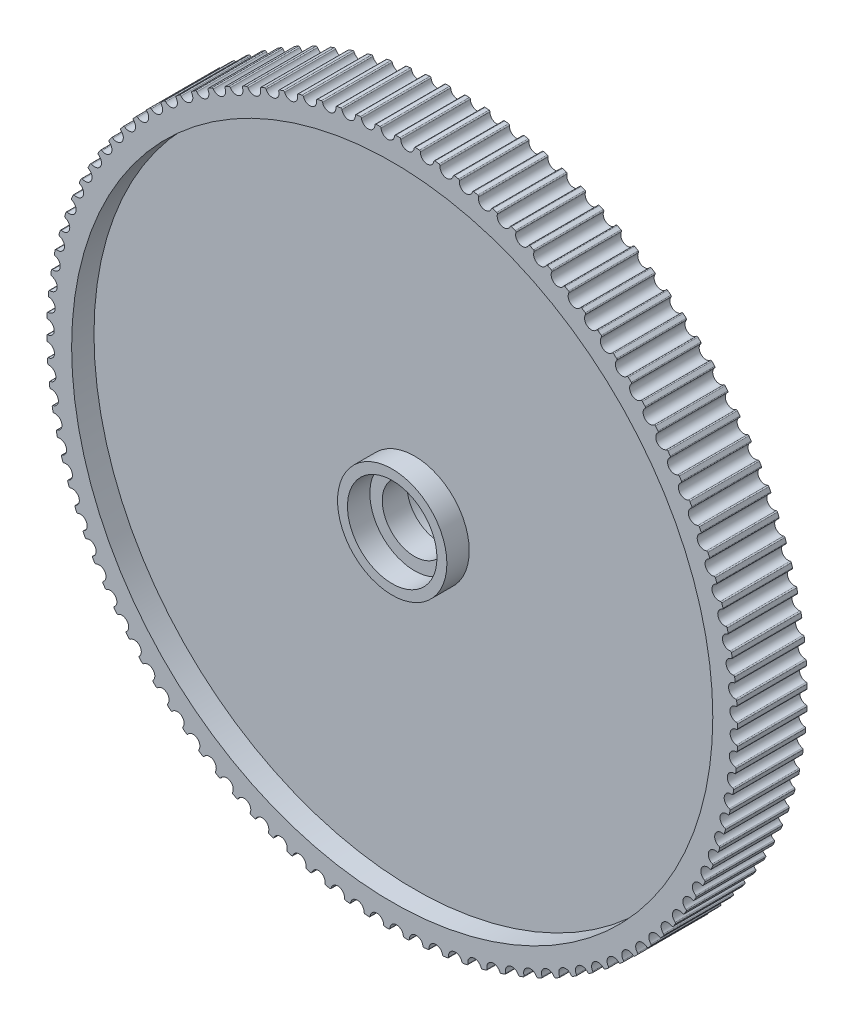
from build123d import *

# Parameters (mm, degrees)
BOSS_EXTRUDE1_DEPTH = 3.5
SKETCH4_R           = 32.25
CUT_EXTRUDE2_DEPTH  = 3.5
SKETCH6_R           = 32.25
SKETCH6_R_2         = 5.5
SKETCH6_R_3         = 4.5
SKETCH6_R_4         = 3.25
BOSS_EXTRUDE2_DEPTH = 1.25
SKETCH6_3_R         = 5.5
SKETCH6_3_R_2       = 4.5
BOSS_EXTRUDE3_DEPTH = 3.5


with BuildPart() as part:
    # Sketch2 → Boss-Extrude1 (new, symmetric)
    with BuildSketch(Plane.XY):
        with BuildLine():
            ThreePointArc((-3.211333328, 34.601298216), (-3.132582306, 34.577768977), (-3.092122191, 34.506226488))
            ThreePointArc((-3.092122191, 34.506226488), (-2.370608918, 33.917255392), (-1.738041502, 34.600868455))
            ThreePointArc((-1.738041502, 34.600868455), (-1.707926922, 34.677343683), (-1.633214692, 34.711599067))
            ThreePointArc((-1.633214692, 34.711599067), (-1.432005901, 34.720481839), (-1.230749008, 34.728198296))
            ThreePointArc((-1.230749008, 34.728198296), (-1.153469677, 34.700211628), (-1.117159824, 34.626475997))
            ThreePointArc((-1.117159824, 34.626475997), (-0.430446923, 33.997275118), (0.240115498, 34.643660757))
            ThreePointArc((0.240115498, 34.643660757), (0.274546844, 34.718292057), (0.351092826, 34.748226341))
            ThreePointArc((0.351092826, 34.748226341), (0.552480572, 34.745607855), (0.75384976, 34.741822211))
            ThreePointArc((0.75384976, 34.741822211), (0.829405331, 34.709469401), (0.861446487, 34.63378114))
            ThreePointArc((0.861446487, 34.63378114), (1.5111191, 33.966402798), (2.217489291, 34.573452638))
            ThreePointArc((2.217489291, 34.573452638), (2.256125096, 34.645996578), (2.334255151, 34.671512123))
            ThreePointArc((2.334255151, 34.671512123), (2.535164969, 34.657400921), (2.735989626, 34.642125523))
            ThreePointArc((2.735989626, 34.642125523), (2.809574991, 34.6055121), (2.837242938, 34.528118086))
            ThreePointArc((2.837242938, 34.528118086), (3.447756167, 33.824739133), (4.187630095, 34.390473103))
            ThreePointArc((4.187630095, 34.390473103), (4.230344336, 34.460693059), (4.309803622, 34.481706639))
            ThreePointArc((4.309803622, 34.481706639), (4.509580184, 34.456148748), (4.709205264, 34.429433422))
            ThreePointArc((4.709205264, 34.429433422), (4.780580401, 34.388678811), (4.803784892, 34.309831489))
            ThreePointArc((4.803784892, 34.309831489), (5.373147369, 33.572746199), (6.14411172, 34.095318993))
            ThreePointArc((6.14411172, 34.095318993), (6.190765072, 34.162985922), (6.271294408, 34.179428995))
            ThreePointArc((6.271294408, 34.179428995), (6.469286087, 34.14250778), (6.667060452, 34.104439666))
            ThreePointArc((6.667060452, 34.104439666), (6.735992552, 34.059676799), (6.754657899, 33.979633352))
            ThreePointArc((6.754657899, 33.979633352), (7.281012482, 33.211245945), (8.080552529, 33.68895304))
            ThreePointArc((8.080552529, 33.68895304), (8.13099282, 33.753846226), (8.212329536, 33.765665158))
            ThreePointArc((8.212329536, 33.765665158), (8.407890523, 33.717501049), (8.603169075, 33.668204316))
            ThreePointArc((8.603169075, 33.668204316), (8.669433295, 33.619579201), (8.683498616, 33.538600714))
            ThreePointArc((8.683498616, 33.538600714), (9.165128446, 32.74141751), (9.990636256, 33.172700723))
            ThreePointArc((9.990636256, 33.172700723), (10.044698959, 33.2346085), (10.126577752, 33.24176474))
            ThreePointArc((10.126577752, 33.24176474), (10.319070167, 33.182514837), (10.511215949, 33.122150282))
            ThreePointArc((10.511215949, 33.122150282), (10.574596148, 33.069821524), (10.584015565, 32.988172132))
            ThreePointArc((10.584015565, 32.988172132), (11.019349666, 32.164793376), (11.868132604, 32.548245952))
            ThreePointArc((11.868132604, 32.548245952), (11.925641377, 32.606966388), (12.007795176, 32.609436594))
            ThreePointArc((12.007795176, 32.609436594), (12.196591149, 32.539294158), (12.384977421, 32.468058678))
            ThreePointArc((12.384977421, 32.468058678), (12.445266867, 32.412196962), (12.450009655, 32.330142989))
            ThreePointArc((12.450009655, 32.330142989), (12.837628057, 31.483254372), (13.70691757, 31.817625568))
            ThreePointArc((13.70691757, 31.817625568), (13.767684832, 31.87296713), (13.849845668, 31.870743245))
            ThreePointArc((13.849845668, 31.870743245), (14.034329387, 31.789937066), (14.21834167, 31.708063015))
            ThreePointArc((14.21834167, 31.708063015), (14.275343712, 31.648850551), (14.275394401, 31.566659639))
            ThreePointArc((14.275394401, 31.566659639), (14.614032774, 30.699023536), (15.50099342, 30.983222703))
            ThreePointArc((15.50099342, 30.983222703), (15.564820961, 31.035004878), (15.646720842, 31.028094155))
            ThreePointArc((15.646720842, 31.028094155), (15.826290558, 30.936887807), (16.005328645, 30.844642241))
            ThreePointArc((16.005328645, 30.844642241), (16.058857353, 30.782272168), (16.054215778, 30.700212407))
            ThreePointArc((16.054215778, 30.700212407), (16.342769554, 29.814658866), (17.244508252, 30.047759005))
            ThreePointArc((17.244508252, 30.047759005), (17.31118788, 30.09581289), (17.392559666, 30.084237871))
            ThreePointArc((17.392559666, 30.084237871), (17.56662966, 29.982928849), (17.740109564, 29.880612655))
            ThreePointArc((17.740109564, 29.880612655), (17.78999034, 29.815288411), (17.78067164, 29.733627463))
            ThreePointArc((17.78067164, 29.733627463), (18.018199616, 28.833044976), (18.931775082, 29.014285763))
            ThreePointArc((18.931775082, 29.014285763), (19.001089301, 29.058454616), (19.081667574, 29.042253056))
            ThreePointArc((19.081667574, 29.042253056), (19.249670067, 28.93117181), (19.417025934, 28.819118722))
            ThreePointArc((19.417025934, 28.819118722), (19.463096075, 28.75105338), (19.449130647, 28.670057606))
            ThreePointArc((19.449130647, 28.670057606), (19.634858056, 27.757383686), (20.557290396, 27.886173951))
            ThreePointArc((20.557290396, 27.886173951), (20.629013119, 27.926313703), (20.708535049, 27.905538449))
            ThreePointArc((20.708535049, 27.905538449), (20.869922051, 27.785047302), (21.030608, 27.663622813))
            ThreePointArc((21.030608, 27.663622813), (21.072717237, 27.59303839), (21.054150632, 27.512971981))
            ThreePointArc((21.054150632, 27.512971981), (21.187471671, 26.59118358), (22.115752103, 26.667103236))
            ThreePointArc((22.115752103, 26.667103236), (22.189649383, 26.70308296), (22.267855587, 26.677801775))
            ThreePointArc((22.267855587, 26.677801775), (22.422100687, 26.548293745), (22.575592595, 26.417893917))
            ThreePointArc((22.575592595, 26.417893917), (22.613603575, 26.345020643), (22.590496355, 26.26614476))
            ThreePointArc((22.590496355, 26.26614476), (22.670976156, 25.338248561), (23.602076822, 25.361049973))
            ThreePointArc((23.602076822, 25.361049973), (23.677907624, 25.39275231), (23.754543009, 25.363047657))
            ThreePointArc((23.754543009, 25.363047657), (23.901143092, 25.224945172), (24.046940299, 25.085995341))
            ThreePointArc((24.046940299, 25.085995341), (24.080729038, 25.011070915), (24.053156573, 24.933642834))
            ThreePointArc((24.053156573, 24.933642834), (24.08053263, 24.002665441), (25.011416473, 23.972274237))
            ThreePointArc((25.011416473, 23.972274237), (25.088933451, 23.99959578), (25.163748048, 23.965564549))
            ThreePointArc((25.163748048, 23.965564549), (25.302224935, 23.81931807), (25.439851882, 23.672271464))
            ThreePointArc((25.439851882, 23.672271464), (25.469308169, 23.595540272), (25.437360394, 23.519812547))
            ThreePointArc((25.437360394, 23.519812547), (25.411543411, 22.588790615), (26.339174082, 22.505305925))
            ThreePointArc((26.339174082, 22.505305925), (26.418124392, 22.528157557), (26.490874172, 22.489910751))
            ThreePointArc((26.490874172, 22.489910751), (26.62077618, 22.335997304), (26.749783955, 22.181333557))
            ThreePointArc((26.749783955, 22.181333557), (26.77481171, 22.103045881), (26.738592833, 22.029265521))
            ThreePointArc((26.738592833, 22.029265521), (26.65966702, 21.10123585), (27.58101878, 20.964929982))
            ThreePointArc((27.58101878, 20.964929982), (27.661144903, 20.983237166), (27.731592571, 20.940899539))
            ThreePointArc((27.731592571, 20.940899539), (27.852495986, 20.779821157), (27.972463794, 20.61804475))
            ThreePointArc((27.972463794, 20.61804475), (27.99298138, 20.538455949), (27.95260954, 20.466863609))
            ThreePointArc((27.95260954, 20.466863609), (27.820832336, 19.544853239), (28.732899927, 19.356170796))
            ThreePointArc((28.732899927, 19.356170796), (28.813940508, 19.369873818), (28.881856278, 19.323583465))
            ThreePointArc((28.881856278, 19.323583465), (28.99336674, 19.155865553), (29.103903269, 18.987504167))
            ThreePointArc((29.103903269, 18.987504167), (29.119843764, 18.906873842), (29.075450644, 18.837703042))
            ThreePointArc((29.075450644, 18.837703042), (28.89125188, 17.924719379), (29.791060327, 17.684275803))
            ThreePointArc((29.791060327, 17.684275803), (29.872751028, 17.693329967), (29.937913374, 17.643237878))
            ThreePointArc((29.937913374, 17.643237878), (30.039667157, 17.469427497), (30.140411862, 17.295030292))
            ThreePointArc((30.140411862, 17.295030292), (30.15172327, 17.213621443), (30.103453672, 17.147097804))
            ThreePointArc((30.103453672, 17.147097804), (29.867434165, 16.24611881), (30.75204848, 15.954698379))
            ThreePointArc((30.75204848, 15.954698379), (30.834122844, 15.959074151), (30.896319219, 15.905343716))
            ThreePointArc((30.896319219, 15.905343716), (30.987984424, 15.7260078), (31.078608696, 15.546143623))
            ThreePointArc((31.078608696, 15.546143623), (31.085254121, 15.464221788), (31.033265491, 15.400562296))
            ThreePointArc((31.033265491, 15.400562296), (30.746195088, 14.514526779), (31.612729843, 14.173080045))
            ThreePointArc((31.612729843, 14.173080045), (31.69492016, 14.172763152), (31.753947692, 14.115569629))
            ThreePointArc((31.753947692, 14.115569629), (31.835225327, 13.931293134), (31.915433568, 13.746548664))
            ThreePointArc((31.915433568, 13.746548664), (31.917391335, 13.664381057), (31.861853248, 13.603793356))
            ThreePointArc((31.861853248, 13.603793356), (31.524668313, 12.735591378), (32.370297052, 12.345232069))
            ThreePointArc((32.370297052, 12.345232069), (32.452335234, 12.340223546), (32.508001388, 12.279753488))
            ThreePointArc((32.508001388, 12.279753488), (32.578626342, 12.091137485), (32.648156929, 11.902115321))
            ThreePointArc((32.648156929, 11.902115321), (32.645420653, 11.819969954), (32.586514263, 11.762651669))
            ThreePointArc((32.586514263, 11.762651669), (32.200314623, 10.915115125), (33.02227908, 10.477116513))
            ThreePointArc((33.02227908, 10.477116513), (33.103897536, 10.467432696), (33.156020741, 10.403883344))
            ThreePointArc((33.156020741, 10.403883344), (33.215762649, 10.211543059), (33.274388789, 10.018859752))
            ThreePointArc((33.274388789, 10.018859752), (33.266967394, 9.937004566), (33.204884841, 9.883142657))
            ThreePointArc((33.204884841, 9.883142657), (32.770930199, 9.059036036), (33.566549298, 8.57482678))
            ThreePointArc((33.566549298, 8.57482678), (33.647481805, 8.560499256), (33.695892045, 8.494077894))
            ThreePointArc((33.695892045, 8.494077894), (33.744556042, 8.298640702), (33.792086508, 8.102924745))
            ThreePointArc((33.792086508, 8.102924745), (33.780004201, 8.021626735), (33.714947986, 7.971396888))
            ThreePointArc((33.714947986, 7.971396888), (33.234653812, 7.173408254), (34.001332409, 6.644567744))
            ThreePointArc((34.001332409, 6.644567744), (34.081314982, 6.625643246), (34.125854354, 6.556566528))
            ThreePointArc((34.125854354, 6.556566528), (34.163281708, 6.358669904), (34.199561465, 6.160559682))
            ThreePointArc((34.199561465, 6.160559682), (34.182857657, 6.080084025), (34.115039979, 6.033650079))
            ThreePointArc((34.115039979, 6.033650079), (33.589972893, 5.264382305), (34.32521024, 4.69263551))
            ThreePointArc((34.32521024, 4.69263551), (34.403981993, 4.669175766), (34.444505218, 4.597669005))
            ThreePointArc((34.444505218, 4.597669005), (34.470573849, 4.397958446), (34.495484561, 4.198100153))
            ThreePointArc((34.495484561, 4.198100153), (34.474213735, 4.118709344), (34.403855803, 4.076222758))
            ThreePointArc((34.403855803, 4.076222758), (33.835728464, 3.338185035), (34.537126371, 2.725396874))
            ThreePointArc((34.537126371, 2.725396874), (34.614430366, 2.697478404), (34.650805266, 2.623774841))
            ThreePointArc((34.650805266, 2.623774841), (34.665430144, 2.422901762), (34.678890556, 2.221947294))
            ThreePointArc((34.678890556, 2.221947294), (34.653122094, 2.143900289), (34.5804534, 2.105499646))
            ThreePointArc((34.5804534, 2.105499646), (33.971118921, 1.401099299), (34.636389574, 0.74926856))
            ThreePointArc((34.636389574, 0.74926856), (34.711973662, 0.716982429), (34.744081589, 0.641322469))
            ThreePointArc((34.744081589, 0.641322469), (34.74721501, 0.439942076), (34.749181219, 0.238546905))
            ThreePointArc((34.749181219, 0.238546905), (34.718999171, 0.162098278), (34.644256745, 0.127908831))
            ThreePointArc((34.644256745, 0.127908831), (33.99570265, -0.540556531), (34.622676073, -1.229303713))
            ThreePointArc((34.622676073, -1.229303713), (34.696293715, -1.265852194), (34.72402994, -1.343221764))
            ThreePointArc((34.72402994, -1.343221764), (34.715661684, -1.544452609), (34.706127275, -1.745631574))
            ThreePointArc((34.706127275, -1.745631574), (34.67163009, -1.820232465), (34.595057726, -1.850099196))
            ThreePointArc((34.595057726, -1.850099196), (33.909399462, -2.480449178), (34.496030599, -3.203866252))
            ThreePointArc((34.496030599, -3.203866252), (34.567441669, -3.24455787), (34.590715723, -3.323384687))
            ThreePointArc((34.590715723, -3.323384687), (34.570873084, -3.523809611), (34.549869157, -3.724116166))
            ThreePointArc((34.549869157, -3.724116166), (34.511169358, -3.796625987), (34.433016819, -3.822072584))
            ThreePointArc((34.433016819, -3.822072584), (33.712490862, -4.412251116), (34.256866244, -5.167978446))
            ThreePointArc((34.256866244, -5.167978446), (34.325837814, -5.212680473), (34.344573781, -5.292707419))
            ThreePointArc((34.344573781, -5.292707419), (34.313321483, -5.491672679), (34.280916548, -5.690453466))
            ThreePointArc((34.280916548, -5.690453466), (34.238140364, -5.760635705), (34.158662568, -5.781579165))
            ThreePointArc((34.158662568, -5.781579165), (33.405619123, -6.329661207), (33.905963111, -7.115233768))
            ThreePointArc((33.905963111, -7.115233768), (33.97227021, -7.163800395), (33.986406977, -7.24476644))
            ThreePointArc((33.986406977, -7.24476644), (33.943846959, -7.441623052), (33.900146714, -7.638229688))
            ThreePointArc((33.900146714, -7.638229688), (33.853433673, -7.705855426), (33.77288986, -7.722227437))
            ThreePointArc((33.77288986, -7.722227437), (32.989785199, -8.226425259), (33.444465774, -9.039280676))
            ThreePointArc((33.444465774, -9.039280676), (33.507892122, -9.09155349), (33.517383579, -9.173194539))
            ThreePointArc((33.517383579, -9.173194539), (33.463654661, -9.367300397), (33.408801648, -9.561091593))
            ThreePointArc((33.408801648, -9.561091593), (33.358304118, -9.625940249), (33.276957005, -9.637687408))
            ThreePointArc((33.276957005, -9.637687408), (32.466345452, -10.096356422), (32.873879542, -10.93384333))
            ThreePointArc((32.873879542, -10.93384333), (32.934218255, -10.989651827), (32.939033441, -11.071701583))
            ThreePointArc((32.939033441, -11.071701583), (32.874310877, -11.262423555), (32.808484015, -11.452767205))
            ThreePointArc((32.808484015, -11.452767205), (32.754366709, -11.514627255), (32.672481633, -11.521711246))
            ThreePointArc((32.672481633, -11.521711246), (31.837007234, -11.933355369), (32.196065547, -12.792742059))
            ThreePointArc((32.196065547, -12.792742059), (32.253119813, -12.851904204), (32.253243023, -12.934095039))
            ThreePointArc((32.253243023, -12.934095039), (32.177737925, -13.120811029), (32.101151926, -13.307086271))
            ThreePointArc((32.101151926, -13.307086271), (32.043591363, -13.365755941), (31.961435416, -13.368153657))
            ThreePointArc((31.961435416, -13.368153657), (31.103823316, -13.731430191), (31.413234678, -14.609913523))
            ThreePointArc((31.413234678, -14.609913523), (31.466818398, -14.67223634), (31.462249231, -14.754300165))
            ThreePointArc((31.462249231, -14.754300165), (31.376207879, -14.936401144), (31.289112552, -15.118000387))
            ThreePointArc((31.289112552, -15.118000387), (31.228296483, -15.173288309), (31.146137641, -15.170991929))
            ThreePointArc((31.146137641, -15.170991929), (30.269185192, -15.484715942), (30.527940367, -16.379430485))
            ThreePointArc((30.527940367, -16.379430485), (30.577878762, -16.444710691), (30.56863212, -16.52637983))
            ThreePointArc((30.56863212, -16.52637983), (30.472335165, -16.703271823), (30.375014597, -16.879602728))
            ThreePointArc((30.375014597, -16.879602728), (30.31114139, -16.931328564), (30.229247639, -16.924345579))
            ThreePointArc((30.229247639, -16.924345579), (29.335815277, -17.187493768), (29.54307026, -18.09552115))
            ThreePointArc((29.54307026, -18.09552115), (29.589200441, -18.163545815), (29.575306486, -18.24455388))
            ThreePointArc((29.575306486, -18.24455388), (29.469068027, -18.415659902), (29.361839657, -18.586147313))
            ThreePointArc((29.361839657, -18.586147313), (29.295117655, -18.634142344), (29.213756114, -18.622495531))
            ThreePointArc((29.213756114, -18.622495531), (28.30675803, -18.834209562), (28.461836798, -19.752587986))
            ThreePointArc((28.461836798, -19.752587986), (28.504008299, -19.823135227), (28.485512349, -19.903217987))
            ThreePointArc((28.485512349, -19.903217987), (28.369678915, -20.067979925), (28.252892499, -20.232067749))
            ThreePointArc((28.252892499, -20.232067749), (28.183539334, -20.276175426), (28.102975388, -20.259902774))
            ThreePointArc((28.102975388, -20.259902774), (27.185370022, -20.419492079), (27.287766741, -21.345225986))
            ThreePointArc((27.287766741, -21.345225986), (27.325842006, -21.418065692), (27.302804391, -21.496961933))
            ThreePointArc((27.302804391, -21.496961933), (27.177753806, -21.654842369), (27.051790279, -21.811995386))
            ThreePointArc((27.051790279, -21.811995386), (26.980032167, -21.852071837), (26.900528599, -21.831226424))
            ThreePointArc((26.900528599, -21.831226424), (25.975308988, -21.938170457), (26.02468966, -22.868240295))
            ThreePointArc((26.02468966, -22.868240295), (26.058544496, -22.943134878), (26.031040361, -23.020587258))
            ThreePointArc((26.031040361, -23.020587258), (25.897180514, -23.171071219), (25.762450741, -23.320776827))
            ThreePointArc((25.762450741, -23.320776827), (25.688521742, -23.356691333), (25.610337876, -23.331341152))
            ThreePointArc((25.610337876, -23.331341152), (24.680521894, -23.385291083), (24.676725451, -24.316663157))
            ThreePointArc((24.676725451, -24.316663157), (24.706249431, -24.393368328), (24.674368488, -24.469124213))
            ThreePointArc((24.674368488, -24.469124213), (24.532136002, -24.61172085), (24.389079444, -24.753490741))
            ThreePointArc((24.389079444, -24.753490741), (24.313220699, -24.785126155), (24.236611554, -24.755353895))
            ThreePointArc((24.236611554, -24.755353895), (23.305232069, -24.75613375), (23.248270892, -25.685770119))
            ThreePointArc((23.248270892, -25.685770119), (23.273367715, -25.76403568), (23.237213953, -25.83784797))
            ThreePointArc((23.237213953, -25.83784797), (23.087072761, -25.972092163), (22.936156039, -26.105463914))
            ThreePointArc((22.936156039, -26.105463914), (22.858614984, -26.132717049), (22.783830443, -26.098619818))
            ThreePointArc((22.783830443, -26.098619818), (21.85392542, -26.046227054), (21.743985306, -26.971095437))
            ThreePointArc((21.743985306, -26.971095437), (21.764573111, -27.050666103), (21.724264456, -27.122294037))
            ThreePointArc((21.724264456, -27.122294037), (21.566704287, -27.24774791), (21.40841966, -27.372286489))
            ThreePointArc((21.40841966, -27.372286489), (21.329449217, -27.39506845), (21.256733213, -27.356757468))
            ThreePointArc((21.256733213, -27.356757468), (20.331335809, -27.251362979), (20.16877536, -28.168446648))
            ThreePointArc((20.16877536, -28.168446648), (20.184786993, -28.249062876), (20.140454924, -28.318272819))
            ThreePointArc((20.140454924, -28.318272819), (19.975989707, -28.434527167), (19.810853466, -28.549826356))
            ThreePointArc((19.810853466, -28.549826356), (19.730711221, -28.568062833), (19.660300937, -28.525663062))
            ThreePointArc((19.660300937, -28.525663062), (18.742429606, -28.367610623), (18.527779061, -29.273918241))
            ThreePointArc((18.527779061, -29.273918241), (18.539162295, -29.355317077), (18.490951414, -29.421883281))
            ThreePointArc((18.490951414, -29.421883281), (18.320117601, -29.528558907), (18.148668386, -29.634242622))
            ThreePointArc((18.148668386, -29.634242622), (18.067615746, -29.647874132), (17.999740847, -29.601523872))
            ThreePointArc((17.999740847, -29.601523872), (17.092389494, -29.391329017), (16.826348997, -30.283904397))
            ThreePointArc((16.826348997, -30.283904397), (16.833066704, -30.365820336), (16.781134264, -30.429525675))
            ThreePointArc((16.781134264, -30.429525675), (16.604489078, -30.526274624), (16.427286122, -30.621998149))
            ThreePointArc((16.427286122, -30.621998149), (16.345587463, -30.630980229), (16.280469342, -30.580830663))
            ThreePointArc((16.280469342, -30.580830663), (15.38659756, -30.319179005), (15.07003488, -31.195110751))
            ThreePointArc((15.07003488, -31.195110751), (15.072065148, -31.2772766), (15.016580542, -31.337913281))
            ThreePointArc((15.016580542, -31.337913281), (14.834700164, -31.42441998), (14.652321465, -31.509871083))
            ThreePointArc((14.652321465, -31.509871083), (14.570243272, -31.514174435), (14.508094331, -31.460389142))
            ThreePointArc((14.508094331, -31.460389142), (13.630617742, -31.148134133), (13.264565442, -32.004565139))
            ThreePointArc((13.264565442, -32.004565139), (13.261901648, -32.086712889), (13.203045856, -32.144083128))
            ThreePointArc((13.203045856, -32.144083128), (13.016523541, -32.220065408), (12.829563981, -32.294965367))
            ThreePointArc((12.829563981, -32.294965367), (12.747373976, -32.294575954), (12.688396932, -32.23733037))
            ThreePointArc((12.688396932, -32.23733037), (11.830177683, -31.875490522), (11.415829748, -32.709627287))
            ThreePointArc((11.415829748, -32.709627287), (11.408480581, -32.791488989), (11.346445578, -32.845405657))
            ThreePointArc((11.346445578, -32.845405657), (11.155889724, -32.910615681), (10.964959126, -32.974720186))
            ThreePointArc((10.964959126, -32.974720186), (10.882925395, -32.969639279), (10.827312619, -32.909120127))
            ThreePointArc((10.827312619, -32.909120127), (9.991150043, -32.498875685), (9.529857991, -33.307997429))
            ThreePointArc((9.529857991, -33.307997429), (9.517847422, -33.389306069), (9.452835553, -33.439593299))
            ThreePointArc((9.452835553, -33.439593299), (9.258867713, -33.493818365), (9.064588853, -33.546918322))
            ThreePointArc((9.064588853, -33.546918322), (8.982978974, -33.537162493), (8.930911862, -33.473567174))
            ThreePointArc((8.930911862, -33.473567174), (8.119533349, -33.016256272), (7.612801817, -33.797723808))
            ThreePointArc((7.612801817, -33.797723808), (7.596169023, -33.878214172), (7.528392344, -33.924707939))
            ThreePointArc((7.528392344, -33.924707939), (7.3316452, -33.967771176), (7.134651776, -34.009693384))
            ThreePointArc((7.134651776, -34.009693384), (7.053731942, -33.995294454), (7.005380328, -33.928830403))
            ThreePointArc((7.005380328, -33.928830403), (6.221432424, -33.425944693), (5.670914266, -34.177209036))
            ThreePointArc((5.670914266, -34.177209036), (5.6497135, -34.256618582), (5.579393083, -34.299167232))
            ThreePointArc((5.579393083, -34.299167232), (5.380508385, -34.330928177), (5.181442947, -34.361535894))
            ThreePointArc((5.181442947, -34.361535894), (5.101477103, -34.34254083), (5.056998699, -34.27342484))
            ThreePointArc((5.056998699, -34.27342484), (4.30303848, -33.72660463), (3.710529372, -34.445215311))
            ThreePointArc((3.710529372, -34.445215311), (3.684829785, -34.523285023), (3.612195002, -34.561749771))
            ThreePointArc((3.612195002, -34.561749771), (3.411821469, -34.582104827), (3.211333328, -34.601298216))
            ThreePointArc((3.211333328, -34.601298216), (3.132582306, -34.577768977), (3.092122191, -34.506226488))
            ThreePointArc((3.092122191, -34.506226488), (2.370608918, -33.917255392), (1.738041502, -34.600868455))
            ThreePointArc((1.738041502, -34.600868455), (1.707926922, -34.677343683), (1.633214692, -34.711599067))
            ThreePointArc((1.633214692, -34.711599067), (1.432005901, -34.720481839), (1.230749008, -34.728198296))
            ThreePointArc((1.230749008, -34.728198296), (1.153469677, -34.700211628), (1.117159824, -34.626475997))
            ThreePointArc((1.117159824, -34.626475997), (0.430446923, -33.997275118), (-0.240115498, -34.643660757))
            ThreePointArc((-0.240115498, -34.643660757), (-0.274546844, -34.718292057), (-0.351092826, -34.748226341))
            ThreePointArc((-0.351092826, -34.748226341), (-0.552480572, -34.745607855), (-0.75384976, -34.741822211))
            ThreePointArc((-0.75384976, -34.741822211), (-0.829405331, -34.709469401), (-0.861446487, -34.63378114))
            ThreePointArc((-0.861446487, -34.63378114), (-1.5111191, -33.966402798), (-2.217489291, -34.573452638))
            ThreePointArc((-2.217489291, -34.573452638), (-2.256125096, -34.645996578), (-2.334255151, -34.671512123))
            ThreePointArc((-2.334255151, -34.671512123), (-2.535164969, -34.657400921), (-2.735989626, -34.642125523))
            ThreePointArc((-2.735989626, -34.642125523), (-2.809574991, -34.6055121), (-2.837242938, -34.528118086))
            ThreePointArc((-2.837242938, -34.528118086), (-3.447756167, -33.824739133), (-4.187630095, -34.390473103))
            ThreePointArc((-4.187630095, -34.390473103), (-4.230344336, -34.460693059), (-4.309803622, -34.481706639))
            ThreePointArc((-4.309803622, -34.481706639), (-4.509580184, -34.456148748), (-4.709205264, -34.429433422))
            ThreePointArc((-4.709205264, -34.429433422), (-4.780580401, -34.388678811), (-4.803784892, -34.309831489))
            ThreePointArc((-4.803784892, -34.309831489), (-5.373147369, -33.572746199), (-6.14411172, -34.095318993))
            ThreePointArc((-6.14411172, -34.095318993), (-6.190765072, -34.162985922), (-6.271294408, -34.179428995))
            ThreePointArc((-6.271294408, -34.179428995), (-6.469286087, -34.14250778), (-6.667060452, -34.104439666))
            ThreePointArc((-6.667060452, -34.104439666), (-6.735992552, -34.059676799), (-6.754657899, -33.979633352))
            ThreePointArc((-6.754657899, -33.979633352), (-7.281012482, -33.211245945), (-8.080552529, -33.68895304))
            ThreePointArc((-8.080552529, -33.68895304), (-8.13099282, -33.753846226), (-8.212329536, -33.765665158))
            ThreePointArc((-8.212329536, -33.765665158), (-8.407890523, -33.717501049), (-8.603169075, -33.668204316))
            ThreePointArc((-8.603169075, -33.668204316), (-8.669433295, -33.619579201), (-8.683498616, -33.538600714))
            ThreePointArc((-8.683498616, -33.538600714), (-9.165128446, -32.74141751), (-9.990636256, -33.172700723))
            ThreePointArc((-9.990636256, -33.172700723), (-10.044698959, -33.2346085), (-10.126577752, -33.24176474))
            ThreePointArc((-10.126577752, -33.24176474), (-10.319070167, -33.182514837), (-10.511215949, -33.122150282))
            ThreePointArc((-10.511215949, -33.122150282), (-10.574596148, -33.069821524), (-10.584015565, -32.988172132))
            ThreePointArc((-10.584015565, -32.988172132), (-11.019349666, -32.164793376), (-11.868132604, -32.548245952))
            ThreePointArc((-11.868132604, -32.548245952), (-11.925641377, -32.606966388), (-12.007795176, -32.609436594))
            ThreePointArc((-12.007795176, -32.609436594), (-12.196591149, -32.539294158), (-12.384977421, -32.468058678))
            ThreePointArc((-12.384977421, -32.468058678), (-12.445266867, -32.412196962), (-12.450009655, -32.330142989))
            ThreePointArc((-12.450009655, -32.330142989), (-12.837628057, -31.483254372), (-13.70691757, -31.817625568))
            ThreePointArc((-13.70691757, -31.817625568), (-13.767684832, -31.87296713), (-13.849845668, -31.870743245))
            ThreePointArc((-13.849845668, -31.870743245), (-14.034329387, -31.789937066), (-14.21834167, -31.708063015))
            ThreePointArc((-14.21834167, -31.708063015), (-14.275343712, -31.648850551), (-14.275394401, -31.566659639))
            ThreePointArc((-14.275394401, -31.566659639), (-14.614032774, -30.699023536), (-15.50099342, -30.983222703))
            ThreePointArc((-15.50099342, -30.983222703), (-15.564820961, -31.035004878), (-15.646720842, -31.028094155))
            ThreePointArc((-15.646720842, -31.028094155), (-15.826290558, -30.936887807), (-16.005328645, -30.844642241))
            ThreePointArc((-16.005328645, -30.844642241), (-16.058857353, -30.782272168), (-16.054215778, -30.700212407))
            ThreePointArc((-16.054215778, -30.700212407), (-16.342769554, -29.814658866), (-17.244508252, -30.047759005))
            ThreePointArc((-17.244508252, -30.047759005), (-17.31118788, -30.09581289), (-17.392559666, -30.084237871))
            ThreePointArc((-17.392559666, -30.084237871), (-17.56662966, -29.982928849), (-17.740109564, -29.880612655))
            ThreePointArc((-17.740109564, -29.880612655), (-17.78999034, -29.815288411), (-17.78067164, -29.733627463))
            ThreePointArc((-17.78067164, -29.733627463), (-18.018199616, -28.833044976), (-18.931775082, -29.014285763))
            ThreePointArc((-18.931775082, -29.014285763), (-19.001089301, -29.058454616), (-19.081667574, -29.042253056))
            ThreePointArc((-19.081667574, -29.042253056), (-19.249670067, -28.93117181), (-19.417025934, -28.819118722))
            ThreePointArc((-19.417025934, -28.819118722), (-19.463096075, -28.75105338), (-19.449130647, -28.670057606))
            ThreePointArc((-19.449130647, -28.670057606), (-19.634858056, -27.757383686), (-20.557290396, -27.886173951))
            ThreePointArc((-20.557290396, -27.886173951), (-20.629013119, -27.926313703), (-20.708535049, -27.905538449))
            ThreePointArc((-20.708535049, -27.905538449), (-20.869922051, -27.785047302), (-21.030608, -27.663622813))
            ThreePointArc((-21.030608, -27.663622813), (-21.072717237, -27.59303839), (-21.054150632, -27.512971981))
            ThreePointArc((-21.054150632, -27.512971981), (-21.187471671, -26.59118358), (-22.115752103, -26.667103236))
            ThreePointArc((-22.115752103, -26.667103236), (-22.189649383, -26.70308296), (-22.267855587, -26.677801775))
            ThreePointArc((-22.267855587, -26.677801775), (-22.422100687, -26.548293745), (-22.575592595, -26.417893917))
            ThreePointArc((-22.575592595, -26.417893917), (-22.613603575, -26.345020643), (-22.590496355, -26.26614476))
            ThreePointArc((-22.590496355, -26.26614476), (-22.670976156, -25.338248561), (-23.602076822, -25.361049973))
            ThreePointArc((-23.602076822, -25.361049973), (-23.677907624, -25.39275231), (-23.754543009, -25.363047657))
            ThreePointArc((-23.754543009, -25.363047657), (-23.901143092, -25.224945172), (-24.046940299, -25.085995341))
            ThreePointArc((-24.046940299, -25.085995341), (-24.080729038, -25.011070915), (-24.053156573, -24.933642834))
            ThreePointArc((-24.053156573, -24.933642834), (-24.08053263, -24.002665441), (-25.011416473, -23.972274237))
            ThreePointArc((-25.011416473, -23.972274237), (-25.088933451, -23.99959578), (-25.163748048, -23.965564549))
            ThreePointArc((-25.163748048, -23.965564549), (-25.302224935, -23.81931807), (-25.439851882, -23.672271464))
            ThreePointArc((-25.439851882, -23.672271464), (-25.469308169, -23.595540272), (-25.437360394, -23.519812547))
            ThreePointArc((-25.437360394, -23.519812547), (-25.411543411, -22.588790615), (-26.339174082, -22.505305925))
            ThreePointArc((-26.339174082, -22.505305925), (-26.418124392, -22.528157557), (-26.490874172, -22.489910751))
            ThreePointArc((-26.490874172, -22.489910751), (-26.62077618, -22.335997304), (-26.749783955, -22.181333557))
            ThreePointArc((-26.749783955, -22.181333557), (-26.77481171, -22.103045881), (-26.738592833, -22.029265521))
            ThreePointArc((-26.738592833, -22.029265521), (-26.65966702, -21.10123585), (-27.58101878, -20.964929982))
            ThreePointArc((-27.58101878, -20.964929982), (-27.661144903, -20.983237166), (-27.731592571, -20.940899539))
            ThreePointArc((-27.731592571, -20.940899539), (-27.852495986, -20.779821157), (-27.972463794, -20.61804475))
            ThreePointArc((-27.972463794, -20.61804475), (-27.99298138, -20.538455949), (-27.95260954, -20.466863609))
            ThreePointArc((-27.95260954, -20.466863609), (-27.820832336, -19.544853239), (-28.732899927, -19.356170796))
            ThreePointArc((-28.732899927, -19.356170796), (-28.813940508, -19.369873818), (-28.881856278, -19.323583465))
            ThreePointArc((-28.881856278, -19.323583465), (-28.99336674, -19.155865553), (-29.103903269, -18.987504167))
            ThreePointArc((-29.103903269, -18.987504167), (-29.119843764, -18.906873842), (-29.075450644, -18.837703042))
            ThreePointArc((-29.075450644, -18.837703042), (-28.89125188, -17.924719379), (-29.791060327, -17.684275803))
            ThreePointArc((-29.791060327, -17.684275803), (-29.872751028, -17.693329967), (-29.937913374, -17.643237878))
            ThreePointArc((-29.937913374, -17.643237878), (-30.039667157, -17.469427497), (-30.140411862, -17.295030292))
            ThreePointArc((-30.140411862, -17.295030292), (-30.15172327, -17.213621443), (-30.103453672, -17.147097804))
            ThreePointArc((-30.103453672, -17.147097804), (-29.867434165, -16.24611881), (-30.75204848, -15.954698379))
            ThreePointArc((-30.75204848, -15.954698379), (-30.834122844, -15.959074151), (-30.896319219, -15.905343716))
            ThreePointArc((-30.896319219, -15.905343716), (-30.987984424, -15.7260078), (-31.078608696, -15.546143623))
            ThreePointArc((-31.078608696, -15.546143623), (-31.085254121, -15.464221788), (-31.033265491, -15.400562296))
            ThreePointArc((-31.033265491, -15.400562296), (-30.746195088, -14.514526779), (-31.612729843, -14.173080045))
            ThreePointArc((-31.612729843, -14.173080045), (-31.69492016, -14.172763152), (-31.753947692, -14.115569629))
            ThreePointArc((-31.753947692, -14.115569629), (-31.835225327, -13.931293134), (-31.915433568, -13.746548664))
            ThreePointArc((-31.915433568, -13.746548664), (-31.917391335, -13.664381057), (-31.861853248, -13.603793356))
            ThreePointArc((-31.861853248, -13.603793356), (-31.524668313, -12.735591378), (-32.370297052, -12.345232069))
            ThreePointArc((-32.370297052, -12.345232069), (-32.452335234, -12.340223546), (-32.508001388, -12.279753488))
            ThreePointArc((-32.508001388, -12.279753488), (-32.578626342, -12.091137485), (-32.648156929, -11.902115321))
            ThreePointArc((-32.648156929, -11.902115321), (-32.645420653, -11.819969954), (-32.586514263, -11.762651669))
            ThreePointArc((-32.586514263, -11.762651669), (-32.200314623, -10.915115125), (-33.02227908, -10.477116513))
            ThreePointArc((-33.02227908, -10.477116513), (-33.103897536, -10.467432696), (-33.156020741, -10.403883344))
            ThreePointArc((-33.156020741, -10.403883344), (-33.215762649, -10.211543059), (-33.274388789, -10.018859752))
            ThreePointArc((-33.274388789, -10.018859752), (-33.266967394, -9.937004566), (-33.204884841, -9.883142657))
            ThreePointArc((-33.204884841, -9.883142657), (-32.770930199, -9.059036036), (-33.566549298, -8.57482678))
            ThreePointArc((-33.566549298, -8.57482678), (-33.647481805, -8.560499256), (-33.695892045, -8.494077894))
            ThreePointArc((-33.695892045, -8.494077894), (-33.744556042, -8.298640702), (-33.792086508, -8.102924745))
            ThreePointArc((-33.792086508, -8.102924745), (-33.780004201, -8.021626735), (-33.714947986, -7.971396888))
            ThreePointArc((-33.714947986, -7.971396888), (-33.234653812, -7.173408254), (-34.001332409, -6.644567744))
            ThreePointArc((-34.001332409, -6.644567744), (-34.081314982, -6.625643246), (-34.125854354, -6.556566528))
            ThreePointArc((-34.125854354, -6.556566528), (-34.163281708, -6.358669904), (-34.199561465, -6.160559682))
            ThreePointArc((-34.199561465, -6.160559682), (-34.182857657, -6.080084025), (-34.115039979, -6.033650079))
            ThreePointArc((-34.115039979, -6.033650079), (-33.589972893, -5.264382305), (-34.32521024, -4.69263551))
            ThreePointArc((-34.32521024, -4.69263551), (-34.403981993, -4.669175766), (-34.444505218, -4.597669005))
            ThreePointArc((-34.444505218, -4.597669005), (-34.470573849, -4.397958446), (-34.495484561, -4.198100153))
            ThreePointArc((-34.495484561, -4.198100153), (-34.474213735, -4.118709344), (-34.403855803, -4.076222758))
            ThreePointArc((-34.403855803, -4.076222758), (-33.835728464, -3.338185035), (-34.537126371, -2.725396874))
            ThreePointArc((-34.537126371, -2.725396874), (-34.614430366, -2.697478404), (-34.650805266, -2.623774841))
            ThreePointArc((-34.650805266, -2.623774841), (-34.665430144, -2.422901762), (-34.678890556, -2.221947294))
            ThreePointArc((-34.678890556, -2.221947294), (-34.653122094, -2.143900289), (-34.5804534, -2.105499646))
            ThreePointArc((-34.5804534, -2.105499646), (-33.971118921, -1.401099299), (-34.636389574, -0.74926856))
            ThreePointArc((-34.636389574, -0.74926856), (-34.711973662, -0.716982429), (-34.744081589, -0.641322469))
            ThreePointArc((-34.744081589, -0.641322469), (-34.74721501, -0.439942076), (-34.749181219, -0.238546905))
            ThreePointArc((-34.749181219, -0.238546905), (-34.718999171, -0.162098278), (-34.644256745, -0.127908831))
            ThreePointArc((-34.644256745, -0.127908831), (-33.99570265, 0.540556531), (-34.622676073, 1.229303713))
            ThreePointArc((-34.622676073, 1.229303713), (-34.696293715, 1.265852194), (-34.72402994, 1.343221764))
            ThreePointArc((-34.72402994, 1.343221764), (-34.715661684, 1.544452609), (-34.706127275, 1.745631574))
            ThreePointArc((-34.706127275, 1.745631574), (-34.67163009, 1.820232465), (-34.595057726, 1.850099196))
            ThreePointArc((-34.595057726, 1.850099196), (-33.909399462, 2.480449178), (-34.496030599, 3.203866252))
            ThreePointArc((-34.496030599, 3.203866252), (-34.567441669, 3.24455787), (-34.590715723, 3.323384687))
            ThreePointArc((-34.590715723, 3.323384687), (-34.570873084, 3.523809611), (-34.549869157, 3.724116166))
            ThreePointArc((-34.549869157, 3.724116166), (-34.511169358, 3.796625987), (-34.433016819, 3.822072584))
            ThreePointArc((-34.433016819, 3.822072584), (-33.712490862, 4.412251116), (-34.256866244, 5.167978446))
            ThreePointArc((-34.256866244, 5.167978446), (-34.325837814, 5.212680473), (-34.344573781, 5.292707419))
            ThreePointArc((-34.344573781, 5.292707419), (-34.313321483, 5.491672679), (-34.280916548, 5.690453466))
            ThreePointArc((-34.280916548, 5.690453466), (-34.238140364, 5.760635705), (-34.158662568, 5.781579165))
            ThreePointArc((-34.158662568, 5.781579165), (-33.405619123, 6.329661207), (-33.905963111, 7.115233768))
            ThreePointArc((-33.905963111, 7.115233768), (-33.97227021, 7.163800395), (-33.986406977, 7.24476644))
            ThreePointArc((-33.986406977, 7.24476644), (-33.943846959, 7.441623052), (-33.900146714, 7.638229688))
            ThreePointArc((-33.900146714, 7.638229688), (-33.853433673, 7.705855426), (-33.77288986, 7.722227437))
            ThreePointArc((-33.77288986, 7.722227437), (-32.989785199, 8.226425259), (-33.444465774, 9.039280676))
            ThreePointArc((-33.444465774, 9.039280676), (-33.507892122, 9.09155349), (-33.517383579, 9.173194539))
            ThreePointArc((-33.517383579, 9.173194539), (-33.463654661, 9.367300397), (-33.408801648, 9.561091593))
            ThreePointArc((-33.408801648, 9.561091593), (-33.358304118, 9.625940249), (-33.276957005, 9.637687408))
            ThreePointArc((-33.276957005, 9.637687408), (-32.466345452, 10.096356422), (-32.873879542, 10.93384333))
            ThreePointArc((-32.873879542, 10.93384333), (-32.934218255, 10.989651827), (-32.939033441, 11.071701583))
            ThreePointArc((-32.939033441, 11.071701583), (-32.874310877, 11.262423555), (-32.808484015, 11.452767205))
            ThreePointArc((-32.808484015, 11.452767205), (-32.754366709, 11.514627255), (-32.672481633, 11.521711246))
            ThreePointArc((-32.672481633, 11.521711246), (-31.837007234, 11.933355369), (-32.196065547, 12.792742059))
            ThreePointArc((-32.196065547, 12.792742059), (-32.253119813, 12.851904204), (-32.253243023, 12.934095039))
            ThreePointArc((-32.253243023, 12.934095039), (-32.177737925, 13.120811029), (-32.101151926, 13.307086271))
            ThreePointArc((-32.101151926, 13.307086271), (-32.043591363, 13.365755941), (-31.961435416, 13.368153657))
            ThreePointArc((-31.961435416, 13.368153657), (-31.103823316, 13.731430191), (-31.413234678, 14.609913523))
            ThreePointArc((-31.413234678, 14.609913523), (-31.466818398, 14.67223634), (-31.462249231, 14.754300165))
            ThreePointArc((-31.462249231, 14.754300165), (-31.376207879, 14.936401144), (-31.289112552, 15.118000387))
            ThreePointArc((-31.289112552, 15.118000387), (-31.228296483, 15.173288309), (-31.146137641, 15.170991929))
            ThreePointArc((-31.146137641, 15.170991929), (-30.269185192, 15.484715942), (-30.527940367, 16.379430485))
            ThreePointArc((-30.527940367, 16.379430485), (-30.577878762, 16.444710691), (-30.56863212, 16.52637983))
            ThreePointArc((-30.56863212, 16.52637983), (-30.472335165, 16.703271823), (-30.375014597, 16.879602728))
            ThreePointArc((-30.375014597, 16.879602728), (-30.31114139, 16.931328564), (-30.229247639, 16.924345579))
            ThreePointArc((-30.229247639, 16.924345579), (-29.335815277, 17.187493768), (-29.54307026, 18.09552115))
            ThreePointArc((-29.54307026, 18.09552115), (-29.589200441, 18.163545815), (-29.575306486, 18.24455388))
            ThreePointArc((-29.575306486, 18.24455388), (-29.469068027, 18.415659902), (-29.361839657, 18.586147313))
            ThreePointArc((-29.361839657, 18.586147313), (-29.295117655, 18.634142344), (-29.213756114, 18.622495531))
            ThreePointArc((-29.213756114, 18.622495531), (-28.30675803, 18.834209562), (-28.461836798, 19.752587986))
            ThreePointArc((-28.461836798, 19.752587986), (-28.504008299, 19.823135227), (-28.485512349, 19.903217987))
            ThreePointArc((-28.485512349, 19.903217987), (-28.369678915, 20.067979925), (-28.252892499, 20.232067749))
            ThreePointArc((-28.252892499, 20.232067749), (-28.183539334, 20.276175426), (-28.102975388, 20.259902774))
            ThreePointArc((-28.102975388, 20.259902774), (-27.185370022, 20.419492079), (-27.287766741, 21.345225986))
            ThreePointArc((-27.287766741, 21.345225986), (-27.325842006, 21.418065692), (-27.302804391, 21.496961933))
            ThreePointArc((-27.302804391, 21.496961933), (-27.177753806, 21.654842369), (-27.051790279, 21.811995386))
            ThreePointArc((-27.051790279, 21.811995386), (-26.980032167, 21.852071837), (-26.900528599, 21.831226424))
            ThreePointArc((-26.900528599, 21.831226424), (-25.975308988, 21.938170457), (-26.02468966, 22.868240295))
            ThreePointArc((-26.02468966, 22.868240295), (-26.058544496, 22.943134878), (-26.031040361, 23.020587258))
            ThreePointArc((-26.031040361, 23.020587258), (-25.897180514, 23.171071219), (-25.762450741, 23.320776827))
            ThreePointArc((-25.762450741, 23.320776827), (-25.688521742, 23.356691333), (-25.610337876, 23.331341152))
            ThreePointArc((-25.610337876, 23.331341152), (-24.680521894, 23.385291083), (-24.676725451, 24.316663157))
            ThreePointArc((-24.676725451, 24.316663157), (-24.706249431, 24.393368328), (-24.674368488, 24.469124213))
            ThreePointArc((-24.674368488, 24.469124213), (-24.532136002, 24.61172085), (-24.389079444, 24.753490741))
            ThreePointArc((-24.389079444, 24.753490741), (-24.313220699, 24.785126155), (-24.236611554, 24.755353895))
            ThreePointArc((-24.236611554, 24.755353895), (-23.305232069, 24.75613375), (-23.248270892, 25.685770119))
            ThreePointArc((-23.248270892, 25.685770119), (-23.273367715, 25.76403568), (-23.237213953, 25.83784797))
            ThreePointArc((-23.237213953, 25.83784797), (-23.087072761, 25.972092163), (-22.936156039, 26.105463914))
            ThreePointArc((-22.936156039, 26.105463914), (-22.858614984, 26.132717049), (-22.783830443, 26.098619818))
            ThreePointArc((-22.783830443, 26.098619818), (-21.85392542, 26.046227054), (-21.743985306, 26.971095437))
            ThreePointArc((-21.743985306, 26.971095437), (-21.764573111, 27.050666103), (-21.724264456, 27.122294037))
            ThreePointArc((-21.724264456, 27.122294037), (-21.566704287, 27.24774791), (-21.40841966, 27.372286489))
            ThreePointArc((-21.40841966, 27.372286489), (-21.329449217, 27.39506845), (-21.256733213, 27.356757468))
            ThreePointArc((-21.256733213, 27.356757468), (-20.331335809, 27.251362979), (-20.16877536, 28.168446648))
            ThreePointArc((-20.16877536, 28.168446648), (-20.184786993, 28.249062876), (-20.140454924, 28.318272819))
            ThreePointArc((-20.140454924, 28.318272819), (-19.975989707, 28.434527167), (-19.810853466, 28.549826356))
            ThreePointArc((-19.810853466, 28.549826356), (-19.730711221, 28.568062833), (-19.660300937, 28.525663062))
            ThreePointArc((-19.660300937, 28.525663062), (-18.742429606, 28.367610623), (-18.527779061, 29.273918241))
            ThreePointArc((-18.527779061, 29.273918241), (-18.539162295, 29.355317077), (-18.490951414, 29.421883281))
            ThreePointArc((-18.490951414, 29.421883281), (-18.320117601, 29.528558907), (-18.148668386, 29.634242622))
            ThreePointArc((-18.148668386, 29.634242622), (-18.067615746, 29.647874132), (-17.999740847, 29.601523872))
            ThreePointArc((-17.999740847, 29.601523872), (-17.092389494, 29.391329017), (-16.826348997, 30.283904397))
            ThreePointArc((-16.826348997, 30.283904397), (-16.833066704, 30.365820336), (-16.781134264, 30.429525675))
            ThreePointArc((-16.781134264, 30.429525675), (-16.604489078, 30.526274624), (-16.427286122, 30.621998149))
            ThreePointArc((-16.427286122, 30.621998149), (-16.345587463, 30.630980229), (-16.280469342, 30.580830663))
            ThreePointArc((-16.280469342, 30.580830663), (-15.38659756, 30.319179005), (-15.07003488, 31.195110751))
            ThreePointArc((-15.07003488, 31.195110751), (-15.072065148, 31.2772766), (-15.016580542, 31.337913281))
            ThreePointArc((-15.016580542, 31.337913281), (-14.834700164, 31.42441998), (-14.652321465, 31.509871083))
            ThreePointArc((-14.652321465, 31.509871083), (-14.570243272, 31.514174435), (-14.508094331, 31.460389142))
            ThreePointArc((-14.508094331, 31.460389142), (-13.630617742, 31.148134133), (-13.264565442, 32.004565139))
            ThreePointArc((-13.264565442, 32.004565139), (-13.261901648, 32.086712889), (-13.203045856, 32.144083128))
            ThreePointArc((-13.203045856, 32.144083128), (-13.016523541, 32.220065408), (-12.829563981, 32.294965367))
            ThreePointArc((-12.829563981, 32.294965367), (-12.747373976, 32.294575954), (-12.688396932, 32.23733037))
            ThreePointArc((-12.688396932, 32.23733037), (-11.830177683, 31.875490522), (-11.415829748, 32.709627287))
            ThreePointArc((-11.415829748, 32.709627287), (-11.408480581, 32.791488989), (-11.346445578, 32.845405657))
            ThreePointArc((-11.346445578, 32.845405657), (-11.155889724, 32.910615681), (-10.964959126, 32.974720186))
            ThreePointArc((-10.964959126, 32.974720186), (-10.882925395, 32.969639279), (-10.827312619, 32.909120127))
            ThreePointArc((-10.827312619, 32.909120127), (-9.991150043, 32.498875685), (-9.529857991, 33.307997429))
            ThreePointArc((-9.529857991, 33.307997429), (-9.517847422, 33.389306069), (-9.452835553, 33.439593299))
            ThreePointArc((-9.452835553, 33.439593299), (-9.258867713, 33.493818365), (-9.064588853, 33.546918322))
            ThreePointArc((-9.064588853, 33.546918322), (-8.982978974, 33.537162493), (-8.930911862, 33.473567174))
            ThreePointArc((-8.930911862, 33.473567174), (-8.119533349, 33.016256272), (-7.612801817, 33.797723808))
            ThreePointArc((-7.612801817, 33.797723808), (-7.596169023, 33.878214172), (-7.528392344, 33.924707939))
            ThreePointArc((-7.528392344, 33.924707939), (-7.3316452, 33.967771176), (-7.134651776, 34.009693384))
            ThreePointArc((-7.134651776, 34.009693384), (-7.053731942, 33.995294454), (-7.005380328, 33.928830403))
            ThreePointArc((-7.005380328, 33.928830403), (-6.221432424, 33.425944693), (-5.670914266, 34.177209036))
            ThreePointArc((-5.670914266, 34.177209036), (-5.6497135, 34.256618582), (-5.579393083, 34.299167232))
            ThreePointArc((-5.579393083, 34.299167232), (-5.380508385, 34.330928177), (-5.181442947, 34.361535894))
            ThreePointArc((-5.181442947, 34.361535894), (-5.101477103, 34.34254083), (-5.056998699, 34.27342484))
            ThreePointArc((-5.056998699, 34.27342484), (-4.30303848, 33.72660463), (-3.710529372, 34.445215311))
            ThreePointArc((-3.710529372, 34.445215311), (-3.684829785, 34.523285023), (-3.612195002, 34.561749771))
            ThreePointArc((-3.612195002, 34.561749771), (-3.411821469, 34.582104827), (-3.211333328, 34.601298216))
        make_face()
    extrude(amount=BOSS_EXTRUDE1_DEPTH, both=True)

    # Sketch4 → Cut-Extrude2 (cut, symmetric)
    with BuildSketch(Plane.XY):
        Circle(SKETCH4_R)
    extrude(amount=CUT_EXTRUDE2_DEPTH, both=True, mode=Mode.SUBTRACT)

    # Sketch6 → Boss-Extrude2 (add, symmetric)
    # profile 1 of 2: a face of its own
    with BuildSketch(Plane.XY):
        Circle(SKETCH6_R)
        Circle(SKETCH6_R_2, mode=Mode.SUBTRACT)
    # profile 2 of 2: a face of its own
    with BuildSketch(Plane.XY):
        Circle(SKETCH6_R_3)
        Circle(SKETCH6_R_4, mode=Mode.SUBTRACT)
    extrude(amount=BOSS_EXTRUDE2_DEPTH, both=True)


with BuildPart() as boss_extrude2_piece_1:
    # of the separate pieces the step leaves, piece 1, a body of its own (boss_extrude2_pieces)
    add(part.part.solids().sort_by_distance((-33.274388789, -10.018859752, -3.5))[0])



with BuildPart() as boss_extrude2_piece_2:
    # of the separate pieces the step leaves, piece 2, a body of its own (boss_extrude2_pieces)
    add(part.part.solids().sort_by_distance((4.5, 0, -1.25))[0])


with BuildPart() as boss_extrude2_piece_1_1:
    add(boss_extrude2_piece_1.part)

    add(boss_extrude2_piece_2.part)  # Boss-Extrude3 merges Boss-Extrude2 piece 2
    # Sketch6_3 → Boss-Extrude3 (add, symmetric)
    with BuildSketch(Plane.XY):
        Circle(SKETCH6_3_R)
        Circle(SKETCH6_3_R_2, mode=Mode.SUBTRACT)
    extrude(amount=BOSS_EXTRUDE3_DEPTH, both=True)


solid = boss_extrude2_piece_1_1.part
